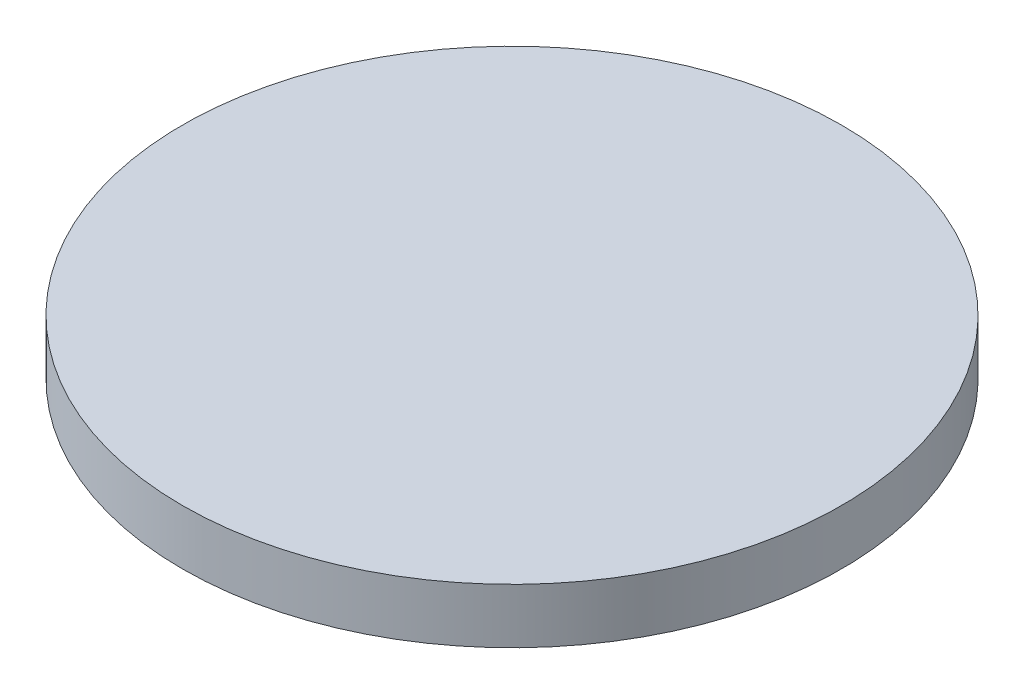
from build123d import *

# Parameters (mm, degrees)
SKETCH1_R           = 3000
BOSS_EXTRUDE1_DEPTH = 500


with BuildPart() as part:
    # Sketch1 → Boss-Extrude1 (new body)
    with BuildSketch(Plane(origin=(0, 0, 0), x_dir=(1, 0, 0), z_dir=(0, 1, 0))):
        Circle(SKETCH1_R)
    extrude(amount=BOSS_EXTRUDE1_DEPTH)


solid = part.part
